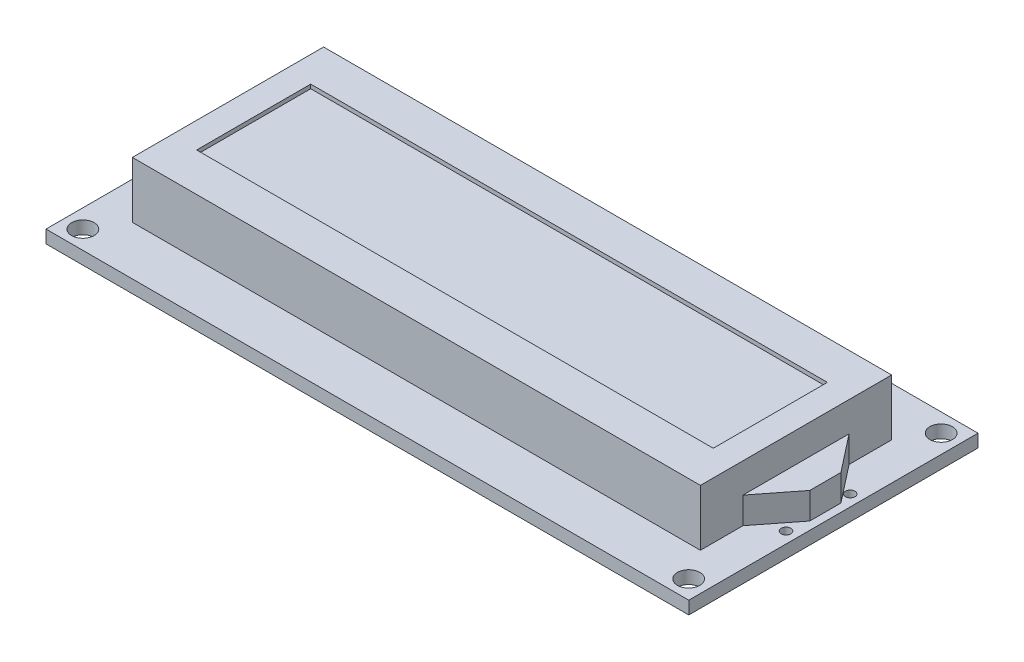
from build123d import *

# Parameters (mm, degrees)
SKETCH1_W           = 80
SKETCH1_H           = 36
SKETCH1_R           = 1.4
BOSS_EXTRUDE1_DEPTH = 1.6
SKETCH2_W           = 70.7
SKETCH2_H           = 23.8
BOSS_EXTRUDE2_DEPTH = 7
SKETCH3_W           = 64.3
SKETCH3_H           = 14.2
CUT_EXTRUDE1_DEPTH  = 0.5
BOSS_EXTRUDE3_DEPTH = 3.3
SKETCH5_R           = 0.6
CUT_EXTRUDE2_DEPTH  = 2.6


with BuildPart() as part:
    # Sketch1 → Boss-Extrude1 (new body)
    with BuildSketch(Plane(origin=(0, 0, 0), x_dir=(1, 0, 0), z_dir=(0, 1, 0))):
        with Locations((40, 18)):
            Rectangle(SKETCH1_W, SKETCH1_H)
        with Locations((2.3, 33.711820065)):
            Circle(SKETCH1_R, mode=Mode.SUBTRACT)
        with Locations((2.3, 2.288179935)):
            Circle(SKETCH1_R, mode=Mode.SUBTRACT)
        with Locations((77.7, 2.288179935)):
            Circle(SKETCH1_R, mode=Mode.SUBTRACT)
        with Locations((77.7, 33.711820065)):
            Circle(SKETCH1_R, mode=Mode.SUBTRACT)
    extrude(amount=BOSS_EXTRUDE1_DEPTH)

    # Sketch2 → Boss-Extrude2 (add)
    with BuildSketch(Plane(origin=(0, 1.6, 0), x_dir=(1, 0, 0), z_dir=(0, 1, 0))):
        with Locations((40, 18)):
            Rectangle(SKETCH2_W, SKETCH2_H)
    extrude(amount=BOSS_EXTRUDE2_DEPTH)

    # Sketch3 → Cut-Extrude1 (cut)
    with BuildSketch(Plane(origin=(0, 8.6, 0), x_dir=(1, 0, 0), z_dir=(0, 1, 0))):
        with Locations((40, 18)):
            Rectangle(SKETCH3_W, SKETCH3_H)
    extrude(amount=-CUT_EXTRUDE1_DEPTH, mode=Mode.SUBTRACT)

    # Sketch4 → Boss-Extrude3 (add)
    with BuildSketch(Plane(origin=(0, 1.6, 0), x_dir=(1, 0, 0), z_dir=(0, 1, 0))):
        Polygon((75.35, 24.6), (79, 19.94), (79, 16.06), (75.35, 11.4), align=None)
    extrude(amount=BOSS_EXTRUDE3_DEPTH)

    # Sketch5 → Cut-Extrude2 (cut, through all)
    with BuildSketch(Plane(origin=(0, 1.6, 0), x_dir=(1, 0, 0), z_dir=(0, 1, 0))):
        with Locations((7.88, 33.65)):
            Circle(SKETCH5_R)
        with Locations((10.42, 33.65)):
            Circle(SKETCH5_R)
        with Locations((12.96, 33.65)):
            Circle(SKETCH5_R)
        with Locations((15.5, 33.65)):
            Circle(SKETCH5_R)
        with Locations((18.04, 33.65)):
            Circle(SKETCH5_R)
        with Locations((20.58, 33.65)):
            Circle(SKETCH5_R)
        with Locations((23.12, 33.65)):
            Circle(SKETCH5_R)
        with Locations((25.66, 33.65)):
            Circle(SKETCH5_R)
        with Locations((28.2, 33.65)):
            Circle(SKETCH5_R)
        with Locations((30.74, 33.65)):
            Circle(SKETCH5_R)
        with Locations((33.28, 33.65)):
            Circle(SKETCH5_R)
        with Locations((35.82, 33.65)):
            Circle(SKETCH5_R)
        with Locations((38.36, 33.65)):
            Circle(SKETCH5_R)
        with Locations((40.9, 33.65)):
            Circle(SKETCH5_R)
        with Locations((43.44, 33.65)):
            Circle(SKETCH5_R)
        with Locations((45.98, 33.65)):
            Circle(SKETCH5_R)
        with Locations((78.6, 21.5)):
            Circle(SKETCH5_R)
        with Locations((78.6, 13.5)):
            Circle(SKETCH5_R)
    extrude(amount=-CUT_EXTRUDE2_DEPTH, mode=Mode.SUBTRACT)


solid = part.part
